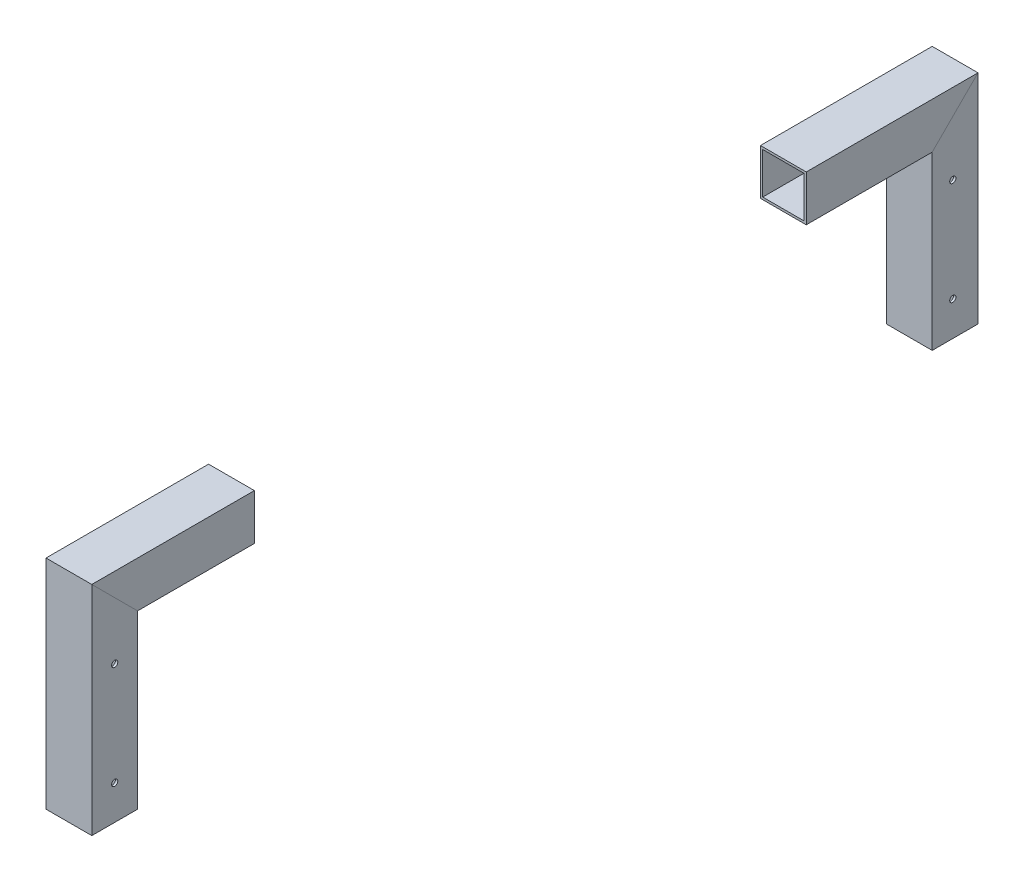
from build123d import *

# Parameters (mm, degrees)
SKETCH_11_W                = 20
SKETCH_11_H                = 20
SKETCH_11_W_2              = 18
SKETCH_11_H_2              = 18
F_20X20X1_1_DEPTH          = 100.142135624
SKETCH_11_ON_SEGMENT_2_W   = 20
SKETCH_11_ON_SEGMENT_2_H   = 20
SKETCH_11_ON_SEGMENT_2_W_2 = 18
SKETCH_11_ON_SEGMENT_2_H_2 = 18
F_20X20X1_1_2_DEPTH        = 397.284271247
SKETCH_11_ON_SEGMENT_3_W   = 20
SKETCH_11_ON_SEGMENT_3_H   = 20
SKETCH_11_ON_SEGMENT_3_W_2 = 18
SKETCH_11_ON_SEGMENT_3_H_2 = 18
F_20X20X1_1_3_DEPTH        = 100.142135624
CUT_EXTRUDE_1_REACH        = 391.299
SKETCH_12_R                = 1.5
SKETCH_14_W                = 241
SKETCH_14_H                = 20
CUT_EXTRUDE_3_DEPTH        = 390.299370665
SKETCH_15_R                = 1.35
CUT_EXTRUDE_4_DEPTH        = 20


with BuildPart() as part:
    # 草图11 → 铝管 20X20X1(1) (new body)
    with BuildSketch(Plane.ZX):
        Rectangle(SKETCH_11_W, SKETCH_11_H)
        Rectangle(SKETCH_11_W_2, SKETCH_11_H_2, mode=Mode.SUBTRACT)
    extrude(amount=F_20X20X1_1_DEPTH)

    # 铝管 20X20X1(1) mitre 1
    split(bisect_by=Plane(origin=(0, 85, 0), x_dir=(1, 0, 0), z_dir=(0, -0.707106781, 0.707106781)), keep=Keep.TOP)


with BuildPart() as body_2:
    # 草图11 on segment 2 (carried to segment 2) → 20X20X1_1 2 (new body)
    with BuildSketch(Plane(origin=(0, 85, 15.142135624), x_dir=(0, 1, 0), z_dir=(0, 0, -1))):
        Rectangle(SKETCH_11_ON_SEGMENT_2_W, SKETCH_11_ON_SEGMENT_2_H)
        Rectangle(SKETCH_11_ON_SEGMENT_2_W_2, SKETCH_11_ON_SEGMENT_2_H_2, mode=Mode.SUBTRACT)
    extrude(amount=F_20X20X1_1_2_DEPTH)

    # 20X20X1_1 2 mitre 1
    split(bisect_by=Plane(origin=(0, 85, 0), x_dir=(-1, 0, 0), z_dir=(0, 0.707106781, -0.707106781)), keep=Keep.TOP)

    # 20X20X1_1 2 mitre 2
    split(bisect_by=Plane(origin=(0, 85, -367), x_dir=(-1, 0, 0), z_dir=(0, 0.707106781, 0.707106781)), keep=Keep.TOP)

    # 切除-拉伸1: up to this face of the body (flat: up to its plane)
    cut_extrude_1_end = Plane(body_2.part.faces().sort_by_distance((-10, 85.181653043, -183.5))[0])
    # 草图12 → 切除-拉伸1 (cut, up to the picked face)
    with BuildSketch(Plane(origin=(10, 0, 0), x_dir=(0, 0, -1), z_dir=(1, 0, 0)), mode=Mode.PRIVATE) as cut_extrude_1_sk1:
        with Locations((133.5, 81)):
            Circle(SKETCH_12_R)
    cut_extrude_1_tool1 = split(extrude(cut_extrude_1_sk1.sketch, amount=-CUT_EXTRUDE_1_REACH, mode=Mode.PRIVATE), bisect_by=cut_extrude_1_end, keep=Keep.BOTH, mode=Mode.PRIVATE)
    # 草图12 → 切除-拉伸1 (cut, up to the picked face)
    with BuildSketch(Plane(origin=(10, 0, 0), x_dir=(0, 0, -1), z_dir=(1, 0, 0)), mode=Mode.PRIVATE) as cut_extrude_1_sk2:
        with Locations((233.5, 81)):
            Circle(SKETCH_12_R)
    cut_extrude_1_tool2 = split(extrude(cut_extrude_1_sk2.sketch, amount=-CUT_EXTRUDE_1_REACH, mode=Mode.PRIVATE), bisect_by=cut_extrude_1_end, keep=Keep.BOTH, mode=Mode.PRIVATE)
    add(cut_extrude_1_tool1.solids().sort_by(Axis((10, 81, -133.5), (-1, 0, 0)))[0], mode=Mode.SUBTRACT)
    add(cut_extrude_1_tool2.solids().sort_by(Axis((10, 81, -233.5), (-1, 0, 0)))[0], mode=Mode.SUBTRACT)

    # 草图14 → 切除-拉伸3 (cut, through all)
    with BuildSketch(Plane(origin=(10, 0, 0), x_dir=(0, 0, -1), z_dir=(1, 0, 0))):
        with Locations((181.5, 85)):
            Rectangle(SKETCH_14_W, SKETCH_14_H)
    extrude(amount=-CUT_EXTRUDE_3_DEPTH, mode=Mode.SUBTRACT)


with BuildPart() as body_3:
    # 草图11 on segment 3 (carried to segment 3) → 20X20X1_1 3 (new body)
    with BuildSketch(Plane(origin=(0, 100.142135624, -367), x_dir=(0, 0, -1), z_dir=(0, -1, 0))):
        Rectangle(SKETCH_11_ON_SEGMENT_3_W, SKETCH_11_ON_SEGMENT_3_H)
        Rectangle(SKETCH_11_ON_SEGMENT_3_W_2, SKETCH_11_ON_SEGMENT_3_H_2, mode=Mode.SUBTRACT)
    extrude(amount=F_20X20X1_1_3_DEPTH)

    # 20X20X1_1 3 mitre 1
    split(bisect_by=Plane(origin=(0, 85, -367), x_dir=(1, 0, 0), z_dir=(0, -0.707106781, -0.707106781)), keep=Keep.TOP)


with BuildPart() as cut_extrude_3_piece_1:
    # of the separate pieces the step leaves, piece 1, a body of its own (cut_extrude_3_pieces)
    add(body_2.part.solids().sort_by_distance((-10, 75, -302))[0])


with BuildPart() as cut_extrude_3_piece_2:
    # of the separate pieces the step leaves, piece 2, a body of its own (cut_extrude_3_pieces)
    add(body_2.part.solids().sort_by_distance((-10, 75, -10))[0])


with BuildPart() as cut_extrude_4_tool:
    # 草图15 → 切除-拉伸4 (new body)
    with BuildSketch(Plane(origin=(10, 0, 0), x_dir=(0, 0, -1), z_dir=(1, 0, 0))):
        with Locations((366, 60)):
            Circle(SKETCH_15_R)
        with Locations((366, 15)):
            Circle(SKETCH_15_R)
        with Locations((0, 60)):
            Circle(SKETCH_15_R)
        with Locations((0, 15)):
            Circle(SKETCH_15_R)
    extrude(amount=-CUT_EXTRUDE_4_DEPTH)


with BuildPart() as part_1:
    add(part.part)

    # 切除-拉伸4: cut by cut_extrude_4_tool
    add(cut_extrude_4_tool.part, mode=Mode.SUBTRACT)


with BuildPart() as body_3_1:
    add(body_3.part)

    # 切除-拉伸4: cut by cut_extrude_4_tool
    add(cut_extrude_4_tool.part, mode=Mode.SUBTRACT)


solid = Compound([cut_extrude_3_piece_1.part, cut_extrude_3_piece_2.part, part_1.part, body_3_1.part])
